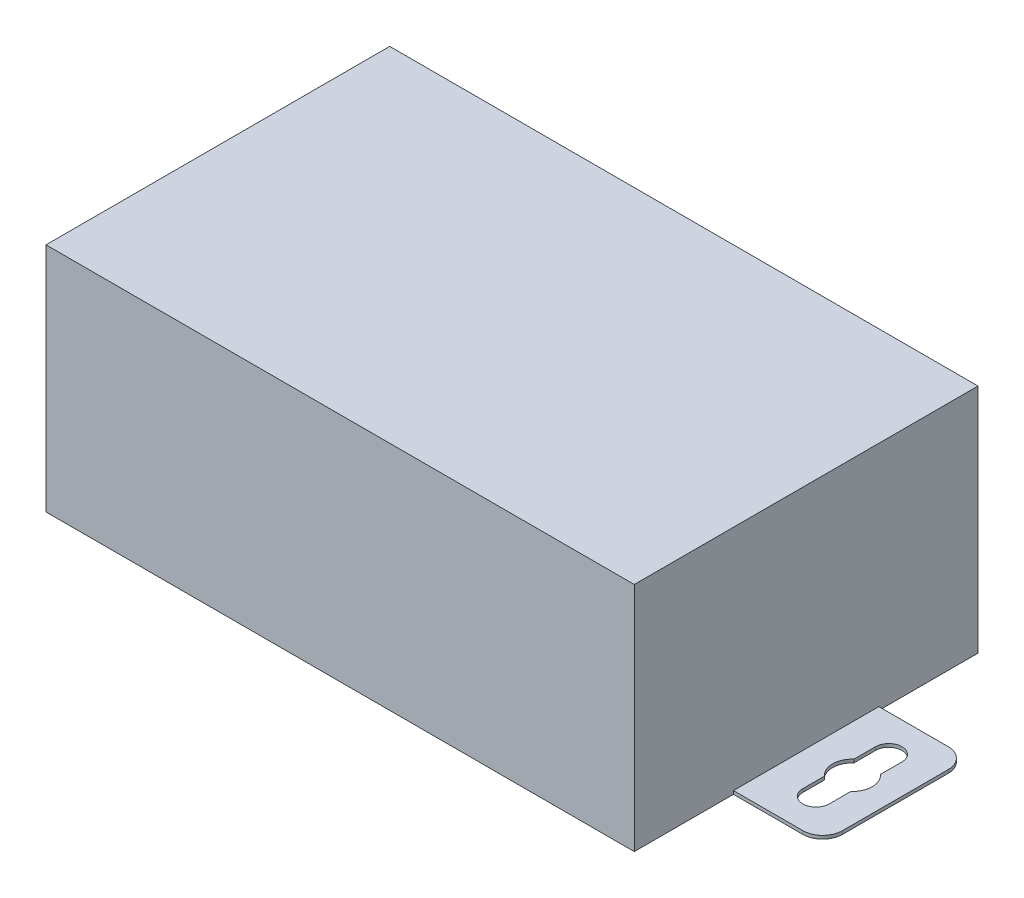
from build123d import *

# Parameters (mm, degrees)
SKETCH_1_W      = 89
SKETCH_1_H      = 52
EXTRUDE_1_DEPTH = 35
EXTRUDE_2_DEPTH = 0.5


with BuildPart() as part:
    # Эскиз1 → Бобышка-Вытянуть1 (new body)
    with BuildSketch(Plane(origin=(0, 0, 0), x_dir=(1, 0, 0), z_dir=(0, 1, 0))):
        with Locations((44.5, 26)):
            Rectangle(SKETCH_1_W, SKETCH_1_H)
    extrude(amount=EXTRUDE_1_DEPTH)

    # Эскиз2 → Бобышка-Вытянуть2 (add)
    with BuildSketch(Plane.XZ):
        with BuildLine():
            Line((-10.5, -37), (13.5, -37))
            Line((13.5, -37), (13.5, -15))
            Line((13.5, -15), (-10.5, -15))
            ThreePointArc((-10.5, -15), (-12.621320344, -15.878679656), (-13.5, -18))
            Line((-13.5, -18), (-13.5, -34))
            ThreePointArc((-13.5, -34), (-12.621320344, -36.121320344), (-10.5, -37))
        make_face()
        with BuildLine():
            Line((-5, -20.5), (-5, -23.763932023))
            ThreePointArc((-5, -23.763932023), (-4, -26), (-5, -28.236067977))
            Line((-5, -28.236067977), (-5, -31.5))
            ThreePointArc((-5, -31.5), (-7, -33.5), (-9, -31.5))
            Line((-9, -31.5), (-9, -28.236067977))
            ThreePointArc((-9, -28.236067977), (-10, -26), (-9, -23.763932023))
            Line((-9, -23.763932023), (-9, -20.5))
            ThreePointArc((-9, -20.5), (-7, -18.5), (-5, -20.5))
        make_face(mode=Mode.SUBTRACT)
        with BuildLine():
            Line((75.5, -37), (75.5, -15))
            Line((75.5, -15), (99.5, -15))
            ThreePointArc((99.5, -15), (101.621320344, -15.878679656), (102.5, -18))
            Line((102.5, -18), (102.5, -34))
            ThreePointArc((102.5, -34), (101.621320344, -36.121320344), (99.5, -37))
            Line((99.5, -37), (75.5, -37))
        make_face()
        with BuildLine():
            Line((98, -28.236067977), (98, -31.5))
            ThreePointArc((98, -31.5), (96, -33.5), (94, -31.5))
            Line((94, -31.5), (94, -28.236067977))
            ThreePointArc((94, -28.236067977), (93, -26), (94, -23.763932022))
            Line((94, -23.763932022), (94, -20.5))
            ThreePointArc((94, -20.5), (96, -18.5), (98, -20.5))
            Line((98, -20.5), (98, -23.763932022))
            ThreePointArc((98, -23.763932022), (99, -26), (98, -28.236067977))
        make_face(mode=Mode.SUBTRACT)
    extrude(amount=-EXTRUDE_2_DEPTH)


solid = part.part
